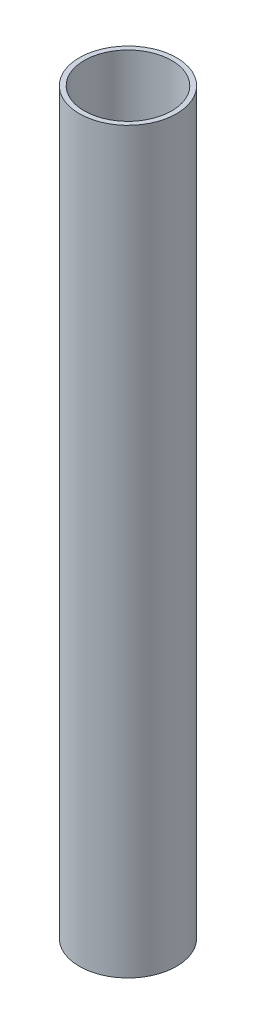
from build123d import *

# Parameters (mm, degrees)
SKETCH1_R           = 20
SKETCH1_R_2         = 18
BOSS_EXTRUDE1_DEPTH = 304


with BuildPart() as part:
    # Sketch1 → Boss-Extrude1 (new body)
    with BuildSketch(Plane(origin=(0, 0, 0), x_dir=(1, 0, 0), z_dir=(0, 1, 0))):
        with Locations((-15.461336204, 4.502108779)):
            Circle(SKETCH1_R)
        with Locations((-15.461336204, 4.502108779)):
            Circle(SKETCH1_R_2, mode=Mode.SUBTRACT)
    extrude(amount=BOSS_EXTRUDE1_DEPTH)


solid = part.part
